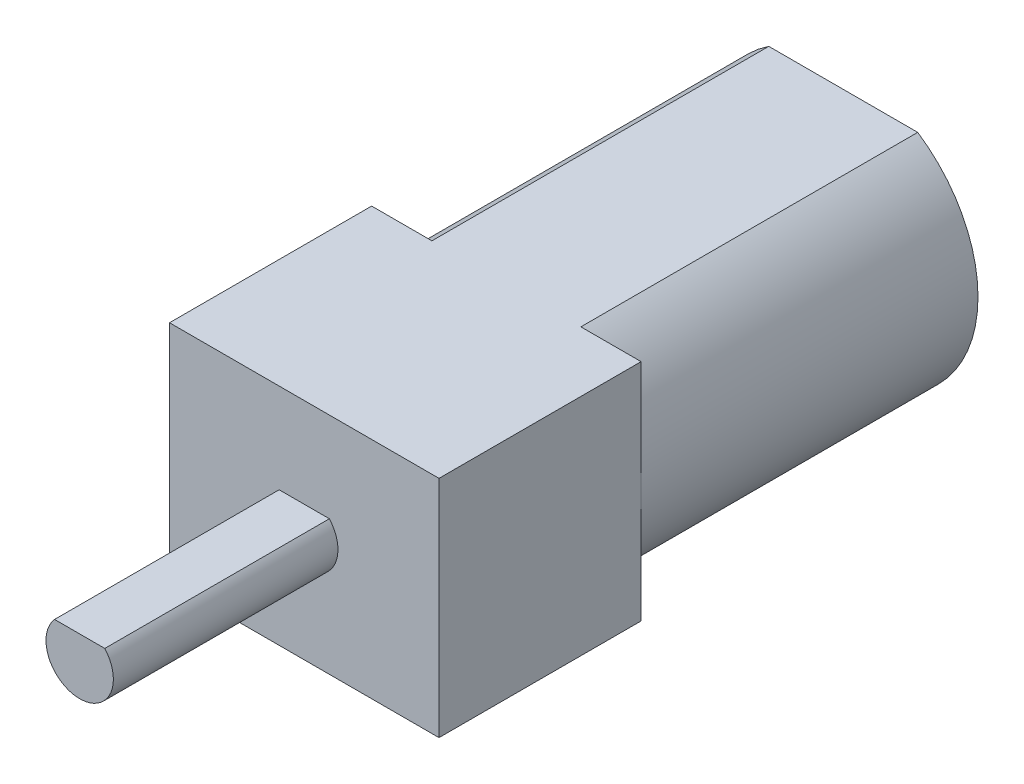
from build123d import *

# Parameters (mm, degrees)
BOSS_EXTRUDE1_DEPTH = 15
ESQUISSE1_W         = 12
ESQUISSE1_H         = 10
BOSS_EXTRU_1_DEPTH  = 9
ESQUISSE2_R         = 2.5
BOSS_EXTRU_2_DEPTH  = 2
BOSS_EXTRUDE2_DEPTH = 10


with BuildPart() as part:
    # Sketch1 → Boss-Extrude1 (new body)
    with BuildSketch(Plane.XY):
        with BuildLine():
            Line((-3.31662479, 5), (3.31662479, 5))
            ThreePointArc((3.31662479, 5), (6, 0), (3.31662479, -5))
            Line((3.31662479, -5), (-3.31662479, -5))
            ThreePointArc((-3.31662479, -5), (-6, 0), (-3.31662479, 5))
        make_face()
    extrude(amount=BOSS_EXTRUDE1_DEPTH)

    # Esquisse1 → Boss.-Extru.1 (add)
    with BuildSketch(Plane.XY.offset(15)):
        Rectangle(ESQUISSE1_W, ESQUISSE1_H)
    extrude(amount=BOSS_EXTRU_1_DEPTH)

    # Esquisse2 → Boss.-Extru.2 (add)
    with BuildSketch(Plane(origin=(0, 0, 0), x_dir=(-1, 0, 0), z_dir=(0, 0, -1))):
        Circle(ESQUISSE2_R)
    extrude(amount=BOSS_EXTRU_2_DEPTH)

    # Sketch2 → Boss-Extrude2 (add)
    with BuildSketch(Plane.XY.offset(24)):
        with BuildLine():
            Line((-1.118033989, 1), (1.118033989, 1))
            ThreePointArc((1.118033989, 1), (0, -1.5), (-1.118033989, 1))
        make_face()
    extrude(amount=BOSS_EXTRUDE2_DEPTH)


solid = part.part
